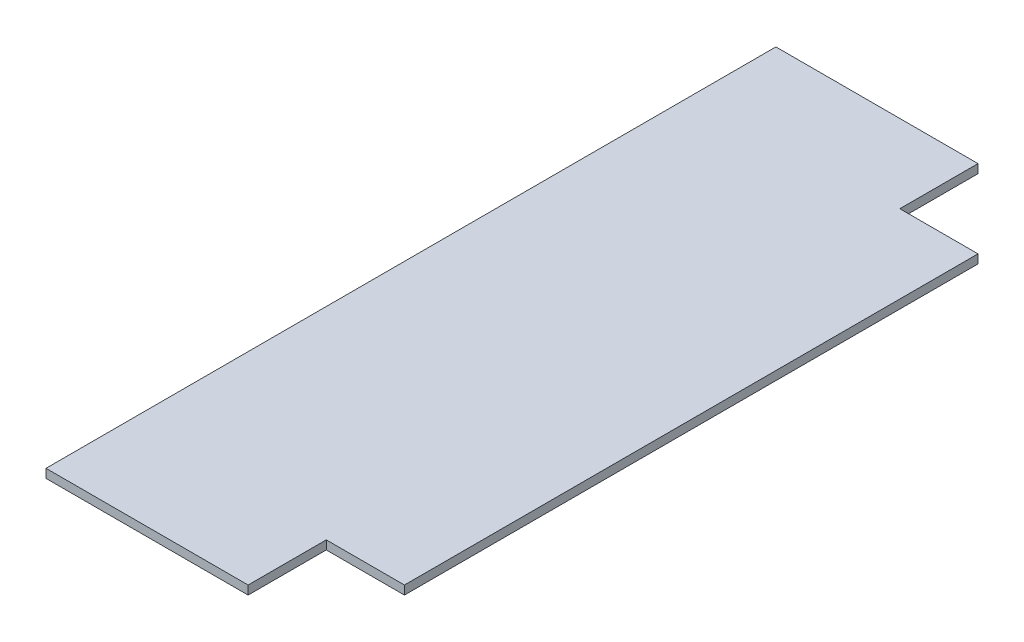
from build123d import *

# Parameters (mm, degrees)
SKETCH1_W           = 152.4
SKETCH1_H           = 396.875
BOSS_EXTRUDE1_DEPTH = 4.7625
SKETCH4_W           = 42.5
SKETCH4_H           = 42.5
CUT_EXTRUDE1_DEPTH  = 5.7625


with BuildPart() as part:
    # Sketch1 → Boss-Extrude1 (new body)
    with BuildSketch(Plane(origin=(0, 0, 0), x_dir=(1, 0, 0), z_dir=(0, 1, 0))):
        with Locations((76.2, -198.4375)):
            Rectangle(SKETCH1_W, SKETCH1_H)
    extrude(amount=BOSS_EXTRUDE1_DEPTH)

    # Sketch4 → Cut-Extrude1 (cut, through all)
    with BuildSketch(Plane(origin=(0, 4.7625, 0), x_dir=(1, 0, 0), z_dir=(0, 1, 0))):
        with Locations((131.15, -21.25)):
            Rectangle(SKETCH4_W, SKETCH4_H)
        with Locations((131.15, -375.625)):
            Rectangle(SKETCH4_W, SKETCH4_H)
    extrude(amount=-CUT_EXTRUDE1_DEPTH, mode=Mode.SUBTRACT)


solid = part.part
